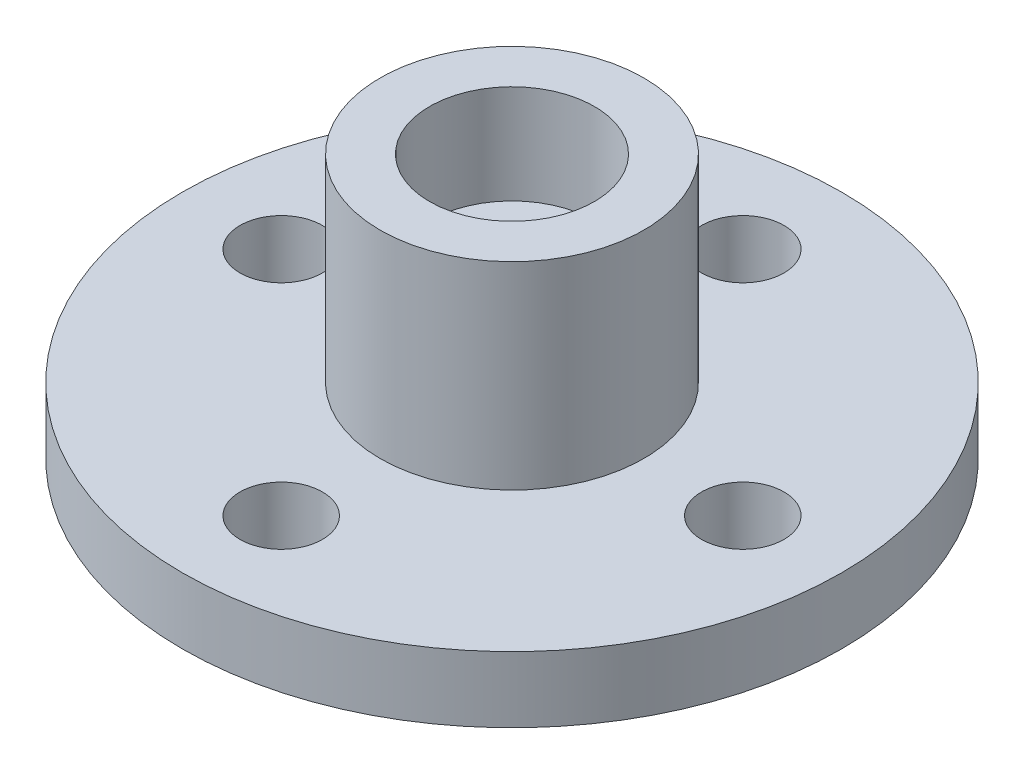
from build123d import *

# Parameters (mm, degrees)
SKETCH1_R                       = 10
BOSS_EXTRUDE1_DEPTH             = 2
TAP_DRILL_FOR_M3X0_5_TAP1_D     = 2.5
TAP_DRILL_FOR_M3X0_5_TAP1_DEPTH = 38.1
CIRPATTERN1_COUNT               = 4
SKETCH4_R                       = 4
BOSS_EXTRUDE2_DEPTH             = 6
SKETCH5_R                       = 2.5
CUT_EXTRUDE1_DEPTH              = 3
TAP_DRILL_FOR_M3X0_5_TAP2_D     = 2.5
TAP_DRILL_FOR_M3X0_5_TAP2_DEPTH = 38.1


with BuildPart() as part:
    # Sketch1 → Boss-Extrude1 (new body)
    with BuildSketch(Plane(origin=(0, 0, 0), x_dir=(1, 0, 0), z_dir=(0, 1, 0))):
        Circle(SKETCH1_R)
    extrude(amount=BOSS_EXTRUDE1_DEPTH)

    # Tap Drill for M3x0.5 Tap1
    with Locations(Plane(origin=(0, 2, 0), x_dir=(1, 0, 0), z_dir=(0, 1, 0))):
        with Locations((7, 0)):
            tap_drill_for_m3x0_5_tap1 = Hole(TAP_DRILL_FOR_M3X0_5_TAP1_D / 2, depth=TAP_DRILL_FOR_M3X0_5_TAP1_DEPTH)

    # CirPattern1: Tap Drill for M3x0.5 Tap1 ×4 about axis
    cirpattern1_axis = Axis((0, 2, 0), (0, -1, 0))
    for i in range(1, CIRPATTERN1_COUNT):
        add(tap_drill_for_m3x0_5_tap1.rotate(cirpattern1_axis, i * 360 / CIRPATTERN1_COUNT), mode=Mode.SUBTRACT)

    # Sketch4 → Boss-Extrude2 (add)
    with BuildSketch(Plane(origin=(0, 2, 0), x_dir=(1, 0, 0), z_dir=(0, 1, 0))):
        Circle(SKETCH4_R)
    extrude(amount=BOSS_EXTRUDE2_DEPTH)

    # Sketch5 → Cut-Extrude1 (cut)
    with BuildSketch(Plane(origin=(0, 8, 0), x_dir=(1, 0, 0), z_dir=(0, 1, 0))):
        Circle(SKETCH5_R)
    extrude(amount=-CUT_EXTRUDE1_DEPTH, mode=Mode.SUBTRACT)

    # Tap Drill for M3x0.5 Tap2
    with Locations(Plane(origin=(0, 5, 0), x_dir=(1, 0, 0), z_dir=(0, 1, 0))):
        with Locations((0, 0)):
            Hole(TAP_DRILL_FOR_M3X0_5_TAP2_D / 2, depth=TAP_DRILL_FOR_M3X0_5_TAP2_DEPTH)


solid = part.part
